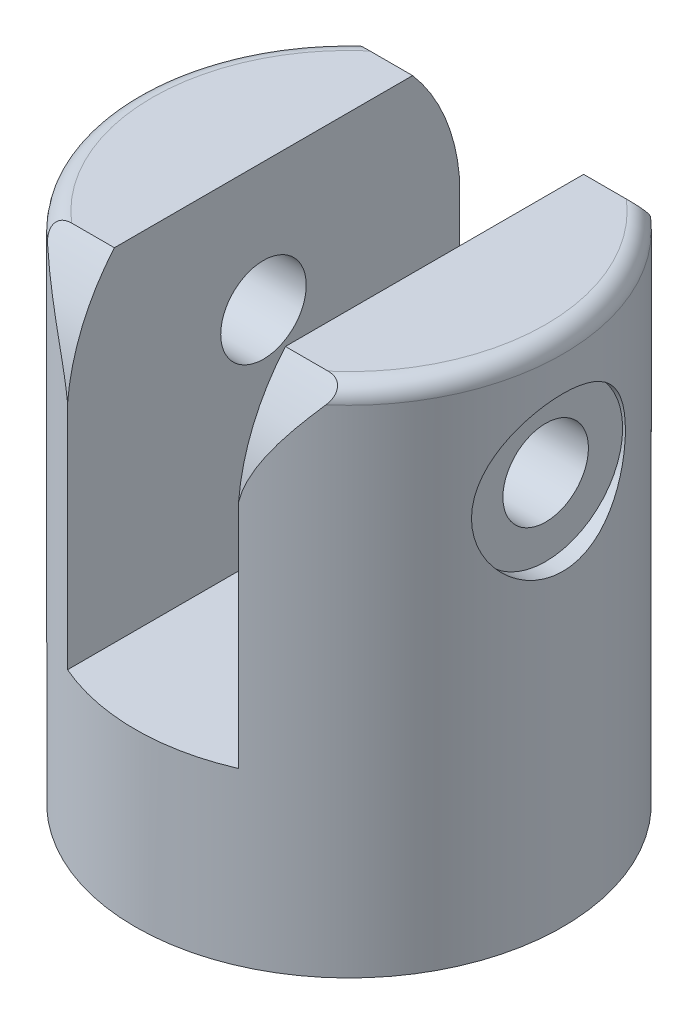
from build123d import *

# Parameters (mm, degrees)
SKETCH1_R               = 125
BOSS_EXTRUDE1_DEPTH     = 300
SKETCH2_W               = 100
SKETCH2_H               = 250
CUT_EXTRUDE1_DEPTH      = 200
SKETCH4_R               = 50
CUT_EXTRUDE3_DEPTH      = 60
SKETCH7_R               = 25
CUT_EXTRUDE6_DEPTH      = 176
CUT_EXTRUDE6_DEPTH_BACK = 76
FILLET2_R               = 10
SKETCH8_R               = 45
SKETCH8_R_2             = 25
CUT_EXTRUDE7_DEPTH      = 10
SKETCH10_R              = 45
SKETCH10_R_2            = 25
CUT_EXTRUDE8_DEPTH      = 10


with BuildPart() as part:
    # Sketch1 → Boss-Extrude1 (new body)
    with BuildSketch(Plane(origin=(0, 0, 0), x_dir=(1, 0, 0), z_dir=(0, 1, 0))):
        Circle(SKETCH1_R)
    extrude(amount=BOSS_EXTRUDE1_DEPTH)

    # Sketch2 → Cut-Extrude1 (cut)
    with BuildSketch(Plane(origin=(0, 300, 0), x_dir=(1, 0, 0), z_dir=(0, 1, 0))):
        Rectangle(SKETCH2_W, SKETCH2_H)
    extrude(amount=-CUT_EXTRUDE1_DEPTH, mode=Mode.SUBTRACT)

    # Sketch4 → Cut-Extrude3 (cut)
    with BuildSketch(Plane.XZ):
        Circle(SKETCH4_R)
    extrude(amount=-CUT_EXTRUDE3_DEPTH, mode=Mode.SUBTRACT)

    # Sketch7 → Cut-Extrude6 (cut, two sides)
    with BuildSketch(Plane(origin=(-50, 0, 0), x_dir=(0, 0, -1), z_dir=(1, 0, 0))) as cut_extrude6_sk:
        with BuildLine():
            Line((-87.177978871, 300), (-114.564392374, 300))
            Line((-114.564392374, 300), (-114.564392374, 235))
            ThreePointArc((-114.564392374, 235), (-105.977573518, 269.651471545), (-87.177978871, 300))
        make_face()
        with BuildLine():
            ThreePointArc((87.177978871, 300), (105.977573518, 269.651471545), (114.564392374, 235))
            Line((114.564392374, 235), (114.564392374, 300))
            Line((114.564392374, 300), (87.177978871, 300))
        make_face()
        with Locations((0, 225)):
            Circle(SKETCH7_R)
    extrude(amount=CUT_EXTRUDE6_DEPTH, mode=Mode.SUBTRACT)
    extrude(cut_extrude6_sk.sketch, amount=-CUT_EXTRUDE6_DEPTH_BACK, mode=Mode.SUBTRACT)

    # Fillet2
    fillet2_edges = [part.edges().sort_by_distance(p)[0] for p in [
        (115.807589436, 300, 47.048934409),
        (-125, 300, 0),
    ]]
    fillet(fillet2_edges, radius=FILLET2_R)

    # Sketch8 → Cut-Extrude7 (cut)
    with BuildSketch(Plane(origin=(-125, 0, 0), x_dir=(0, 0, -1), z_dir=(1, 0, 0))):
        with Locations((0, 225)):
            Circle(SKETCH8_R)
        with Locations((0, 225)):
            Circle(SKETCH8_R_2, mode=Mode.SUBTRACT)
    extrude(amount=CUT_EXTRUDE7_DEPTH, mode=Mode.SUBTRACT)

    # Sketch10 → Cut-Extrude8 (cut)
    with BuildSketch(Plane.ZY.offset(-125)):
        with Locations((0, 225)):
            Circle(SKETCH10_R)
        with Locations((0, 225)):
            Circle(SKETCH10_R_2, mode=Mode.SUBTRACT)
    extrude(amount=CUT_EXTRUDE8_DEPTH, mode=Mode.SUBTRACT)


solid = part.part
